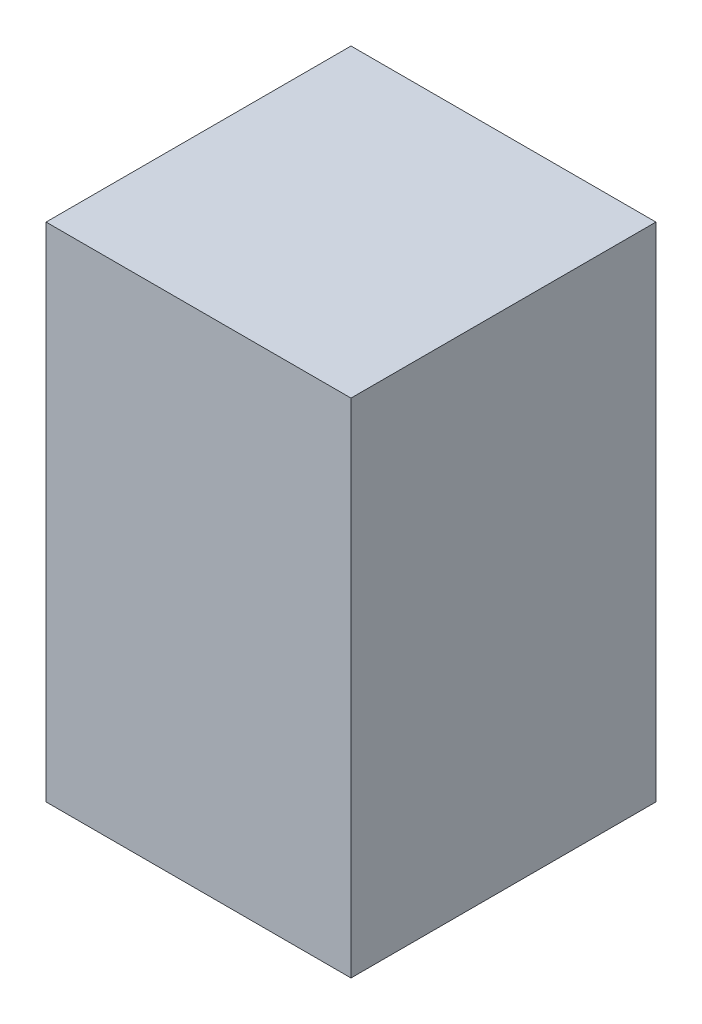
from build123d import *

# Parameters (mm, degrees)
SKETCH1_W      = 86.36
SKETCH1_H      = 86.36
EXTRUDE1_DEPTH = 142.24


with BuildPart() as part:
    # Sketch1 → Extrude1 (new body)
    with BuildSketch(Plane(origin=(0, 0, 0), x_dir=(1, 0, 0), z_dir=(0, 1, 0))):
        with Locations((43.18, 43.18)):
            Rectangle(SKETCH1_W, SKETCH1_H)
    extrude(amount=EXTRUDE1_DEPTH)


solid = part.part
